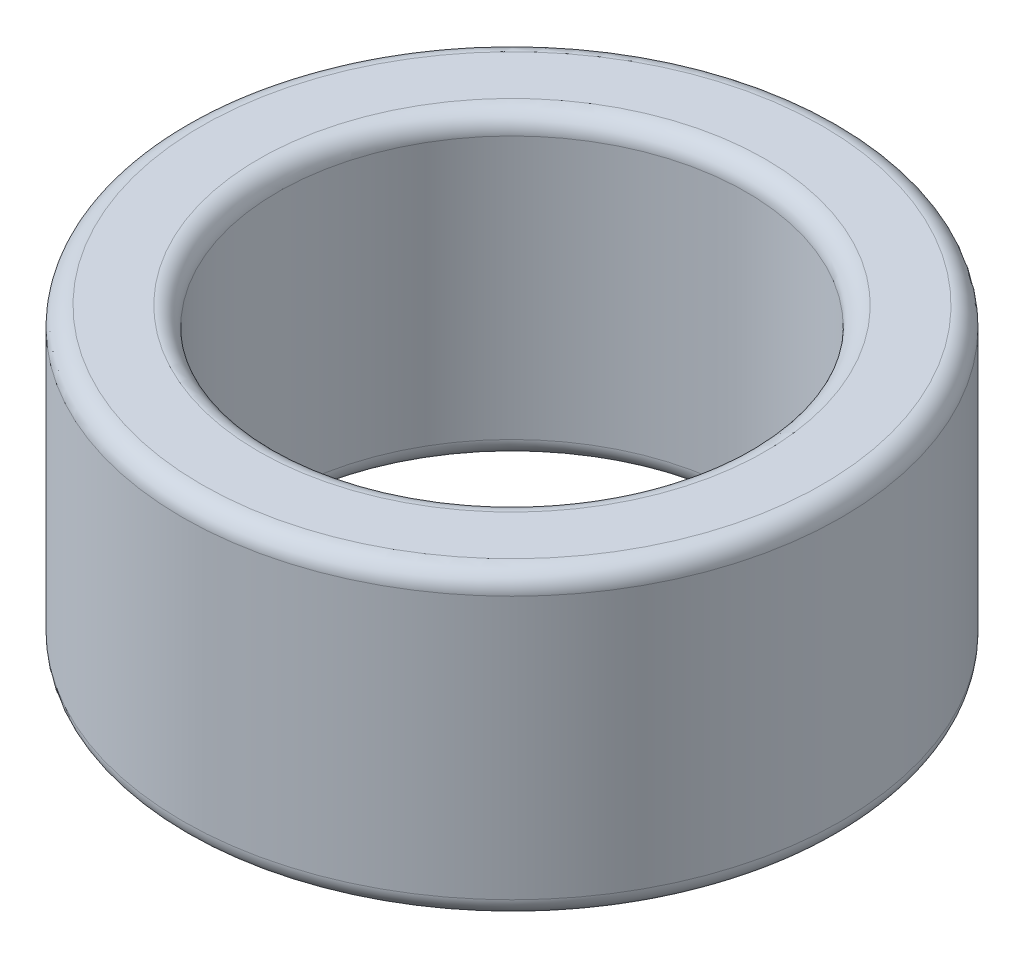
from build123d import *

# Parameters (mm, degrees)
SKETCH1_R           = 2.1971
SKETCH1_R_2         = 1.5621
BOSS_EXTRUDE1_DEPTH = 2.0066
FILLET1_R           = 0.127


with BuildPart() as part:
    # Sketch1 → Boss-Extrude1 (new body)
    with BuildSketch(Plane(origin=(0, 0, 0), x_dir=(1, 0, 0), z_dir=(0, 1, 0))):
        Circle(SKETCH1_R)
        Circle(SKETCH1_R_2, mode=Mode.SUBTRACT)
    extrude(amount=BOSS_EXTRUDE1_DEPTH)

    # Fillet1
    fillet1_edges = [part.edges().sort_by_distance(p)[0] for p in [
        (-2.1971, 0, 0),
        (-2.1971, 2.0066, 0),
        (-1.5621, 0, 0),
        (-1.5621, 2.0066, 0),
    ]]
    fillet(fillet1_edges, radius=FILLET1_R)


solid = part.part
